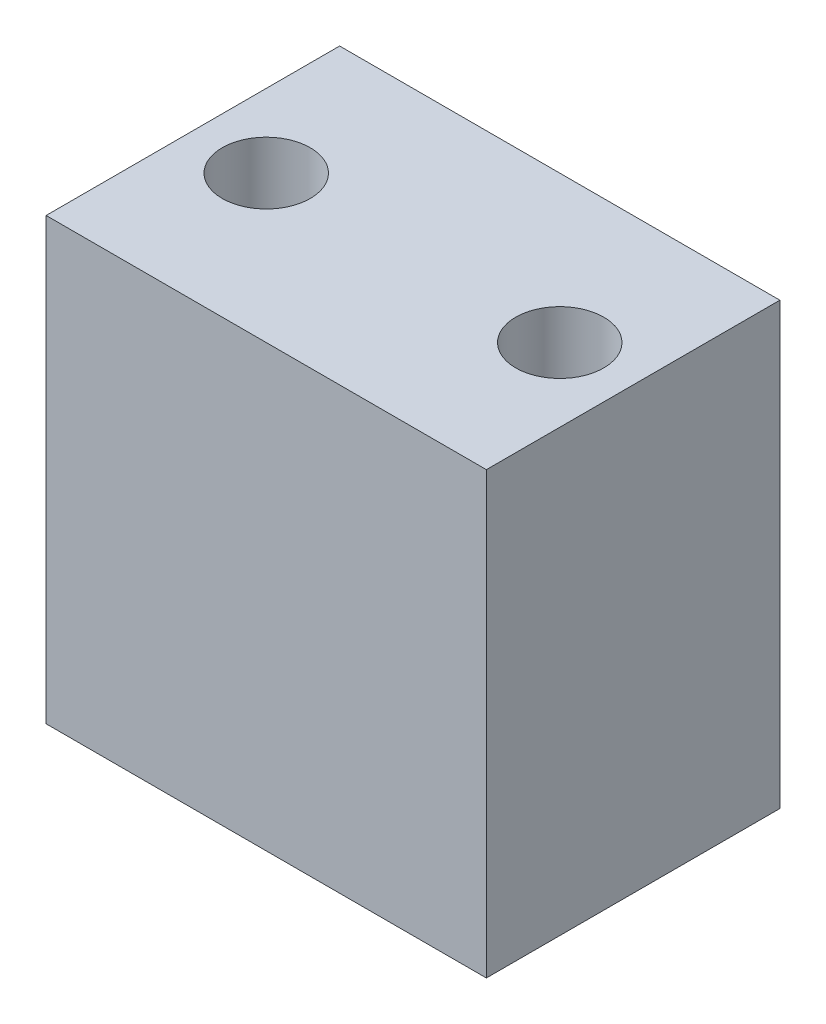
from build123d import *

# Parameters (mm, degrees)
SKETCH1_W           = 38.1
SKETCH1_H           = 25.4
SKETCH1_R           = 3.81
BOSS_EXTRUDE1_DEPTH = 38.1


with BuildPart() as part:
    # Sketch1 → Boss-Extrude1 (new body)
    with BuildSketch(Plane(origin=(0, 0, 0), x_dir=(1, 0, 0), z_dir=(0, 1, 0))):
        with Locations((-19.05, 12.7)):
            Rectangle(SKETCH1_W, SKETCH1_H)
        with Locations((-31.75, 12.7)):
            Circle(SKETCH1_R, mode=Mode.SUBTRACT)
        with Locations((-6.35, 12.7)):
            Circle(SKETCH1_R, mode=Mode.SUBTRACT)
    extrude(amount=BOSS_EXTRUDE1_DEPTH)


solid = part.part
